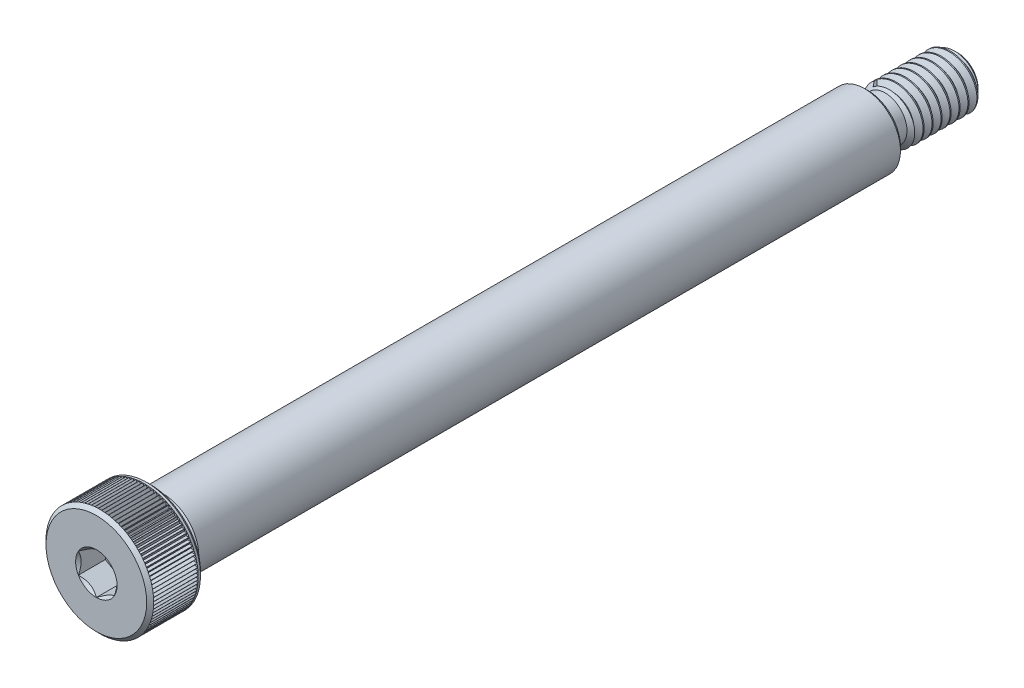
from build123d import *

# Parameters (mm, degrees)
CUT_EXTRUDE1_START     = 24
CUT_EXTRUDE1_DEPTH     = 1.5
CHAMFER1_SIZE          = 0.195
CUT_SWEEP1_PITCH       = 0.5
CUT_SWEEP1_HEIGHT      = 4.05
CUT_SWEEP1_RADIUS      = 1.5
CUT_SWEEP1_START_ANGLE = 90
CUT_EXTRUDE3_START     = 23.805
CUT_EXTRUDE3_DEPTH     = 2.4795
CIRPATTERN1_COUNT      = 99


with BuildPart() as part:
    # Sketch3 → Revolve1 (revolve)
    with BuildSketch(Plane(origin=(0, 0, 0), x_dir=(0, 0, -1), z_dir=(1, 0, 0)), mode=Mode.PRIVATE) as revolve1_sk:
        with BuildLine():
            Line((-24, 0), (-24, 2.805))
            Line((-24, 2.805), (-23.805, 3))
            Line((-23.805, 3), (-21.195, 3))
            Line((-21.195, 3), (-21, 2.805))
            Line((-21, 2.805), (-21, 1.797))
            Line((-21, 1.797), (-20.492, 1.797))
            Line((-20.492, 1.797), (-20.289, 2))
            Line((-20.289, 2), (19, 2))
            Line((19, 2), (19, 1.359375))
            ThreePointArc((19, 1.359375), (19.041188109, 1.259938109), (19.140625, 1.21875))
            Line((19.140625, 1.21875), (19.95, 1.21875))
            Line((19.95, 1.21875), (20.23125, 1.5))
            Line((20.23125, 1.5), (23.625, 1.5))
            Line((23.625, 1.5), (24, 1.125))
            Line((24, 1.125), (24, 0))
            Line((24, 0), (-24, 0))
        make_face()
    revolve(revolve1_sk.sketch.rotate(Axis((0, 0, 24), (0, 0, -1)), 90), axis=Axis((0, 0, 24), (0, 0, -1)))

    # Sketch4 → Cut-Extrude1 (cut)
    with BuildSketch(Plane.XY.offset(CUT_EXTRUDE1_START)):
        Polygon((0, 1.154700538), (-1, 0.577350269), (-1, -0.577350269), (0, -1.154700538), (1, -0.577350269), (1, 0.577350269), align=None)
    extrude(amount=-CUT_EXTRUDE1_DEPTH, mode=Mode.SUBTRACT)

    # Cut-Extrude2 cone 1 section (through the dimple's axis) → Cut-Extrude2 (revolve, cut)
    with BuildSketch(Plane(origin=(0, 0, 24), x_dir=(0, -1, 0), z_dir=(1, 0, 0))):
        Polygon((0, 0), (1.154700538, 0), (0, 1.154700538), align=None)
    revolve(axis=Axis((0, 0, 24), (0, 0, -1)), mode=Mode.SUBTRACT)

    # Chamfer1
    chamfer1_edges = [part.edges().sort_by_distance(p)[0] for p in [
        (-2, 0, -19),
    ]]
    chamfer(chamfer1_edges, length=CHAMFER1_SIZE)

    # Cut-Sweep1: sweep along a helix
    with BuildLine() as cut_sweep1_path:
        add(Helix(CUT_SWEEP1_PITCH, CUT_SWEEP1_HEIGHT, CUT_SWEEP1_RADIUS, center=(0, 0, -24), direction=(0, 0, 1), mode=Mode.PRIVATE).rotate(Axis((0, 0, -24), (0, 0, 1)), CUT_SWEEP1_START_ANGLE))
    # Sketch7 → Cut-Sweep1 (sweep, cut)
    with BuildSketch(Plane(origin=(0, 0, 0), x_dir=(0, 0, -1), z_dir=(1, 0, 0))):
        Polygon((23.984375, 1.527063294), (24.1875, 1.175240474), (24.25, 1.175240474), (24.453125, 1.527063294), align=None)
    sweep(path=cut_sweep1_path.line, is_frenet=True, mode=Mode.SUBTRACT)

    # Sketch8 → Cut-Extrude3 (cut)
    with BuildSketch(Plane.XY.offset(CUT_EXTRUDE3_START)):
        Polygon((-0.090066642, 3), (0.090066642, 3), (0, 2.844), align=None)
    cut_extrude3 = extrude(amount=-CUT_EXTRUDE3_DEPTH, mode=Mode.SUBTRACT)

    # CirPattern1: Cut-Extrude3 ×99 about axis
    cirpattern1_axis = Axis((0, 0, 0), (0, 0, 1))
    for i in range(1, CIRPATTERN1_COUNT):
        add(cut_extrude3.rotate(cirpattern1_axis, i * 360 / CIRPATTERN1_COUNT), mode=Mode.SUBTRACT)


solid = part.part
